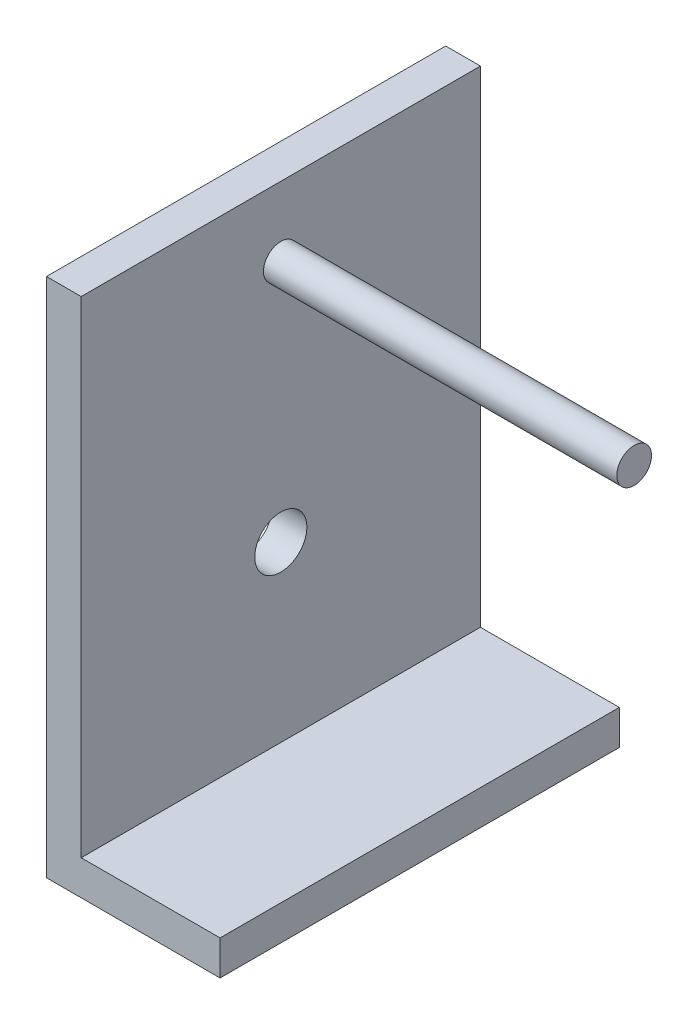
from build123d import *

# Parameters (mm, degrees)
BOSS_EXTRUDE1_DEPTH = 57.5
SKETCH2_R           = 7.5
CUT_EXTRUDE1_DEPTH  = 51
SKETCH3_R           = 5
BOSS_EXTRUDE2_DEPTH = 101.780663763


with BuildPart() as part:
    # Sketch1 → Boss-Extrude1 (new body, symmetric)
    with BuildSketch(Plane.XY):
        Polygon((0, 150), (0, 0), (50, 0), (50, 10), (10, 10), (10, 150), align=None)
    extrude(amount=BOSS_EXTRUDE1_DEPTH, both=True)

    # Sketch2 → Cut-Extrude1 (cut, through all)
    with BuildSketch(Plane.ZY):
        with Locations((0, 60)):
            Circle(SKETCH2_R)
    extrude(amount=-CUT_EXTRUDE1_DEPTH, mode=Mode.SUBTRACT)

    # Sketch3 → Boss-Extrude2 (add)
    with BuildSketch(Plane(origin=(10, 0, 0), x_dir=(0, 0, -1), z_dir=(1, 0, 0))):
        with Locations((0, 130)):
            Circle(SKETCH3_R)
    extrude(amount=BOSS_EXTRUDE2_DEPTH)


solid = part.part
